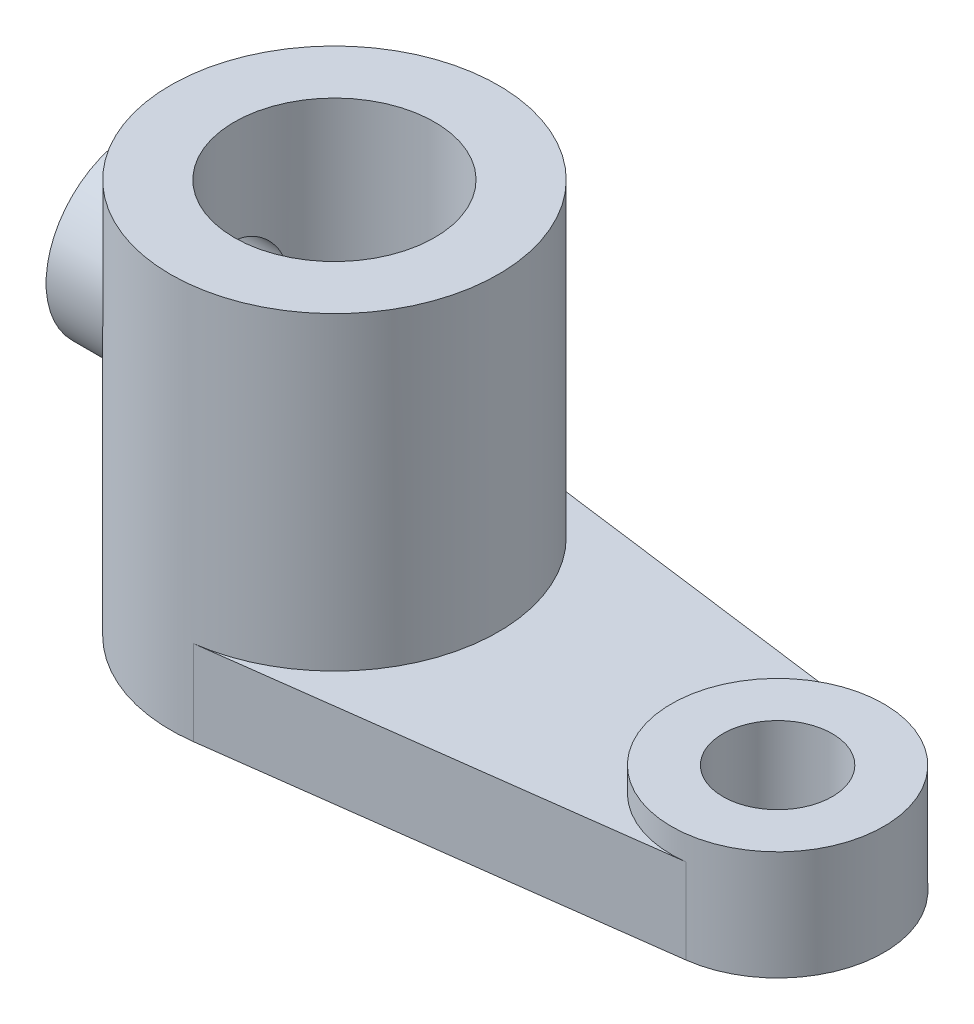
from build123d import *

# Parameters (mm, degrees)
EXTRUDE_1_DEPTH     = 14
SKETCH_2_R          = 27
EXTRUDE_2_DEPTH     = 65
SKETCH_3_R          = 17.5
EXTRUDE_3_DEPTH     = 18
SKETCH_4_R          = 14.5
EXTRUDE_4_DEPTH     = 33
SKETCH_5_R          = 16.5
CUT_EXTRUDE_1_DEPTH = 66.0000001
SKETCH_6_R          = 9
CUT_EXTRUDE_2_DEPTH = 19.0000001
SKETCH_7_R          = 7
CUT_EXTRUDE_3_DEPTH = 33


with BuildPart() as part:
    # 草图1 → 凸台-拉伸1 (new body)
    with BuildSketch(Plane(origin=(0, 0, 0), x_dir=(1, 0, 0), z_dir=(0, 1, 0))):
        with BuildLine():
            Line((3.51369863, -26.770392637), (75.27739726, -17.351180413))
            ThreePointArc((75.27739726, -17.351180413), (90.5, 0), (75.27739726, 17.351180413))
            Line((75.27739726, 17.351180413), (3.51369863, 26.770392637))
            ThreePointArc((3.51369863, 26.770392637), (-27, 0), (3.51369863, -26.770392637))
        make_face()
    extrude(amount=EXTRUDE_1_DEPTH)

    # 草图2 → 凸台-拉伸2 (add)
    with BuildSketch(Plane(origin=(0, 0, 0), x_dir=(1, 0, 0), z_dir=(0, 1, 0))):
        Circle(SKETCH_2_R)
    extrude(amount=EXTRUDE_2_DEPTH)

    # 草图3 → 凸台-拉伸3 (add)
    with BuildSketch(Plane(origin=(0, 0, 0), x_dir=(1, 0, 0), z_dir=(0, 1, 0))):
        with Locations((73, 0)):
            Circle(SKETCH_3_R)
    extrude(amount=EXTRUDE_3_DEPTH)

    # 草图4 → 凸台-拉伸4 (add)
    with BuildSketch(Plane(origin=(0, 0, 0), x_dir=(0, 0, -1), z_dir=(1, 0, 0))):
        with Locations((0, 41)):
            Circle(SKETCH_4_R)
    extrude(amount=-EXTRUDE_4_DEPTH)

    # 草图5 → 切除-拉伸1 (cut, through all)
    with BuildSketch(Plane(origin=(0, 65, 0), x_dir=(1, 0, 0), z_dir=(0, 1, 0))):
        Circle(SKETCH_5_R)
    extrude(amount=-CUT_EXTRUDE_1_DEPTH, mode=Mode.SUBTRACT)

    # 草图6 → 切除-拉伸2 (cut, through all)
    with BuildSketch(Plane(origin=(0, 18, 0), x_dir=(1, 0, 0), z_dir=(0, 1, 0))):
        with Locations((73, 0)):
            Circle(SKETCH_6_R)
    extrude(amount=-CUT_EXTRUDE_2_DEPTH, mode=Mode.SUBTRACT)

    # 草图7 → 切除-拉伸3 (cut)
    with BuildSketch(Plane.ZY.offset(33)):
        with Locations((0, 41)):
            Circle(SKETCH_7_R)
    extrude(amount=-CUT_EXTRUDE_3_DEPTH, mode=Mode.SUBTRACT)


solid = part.part
